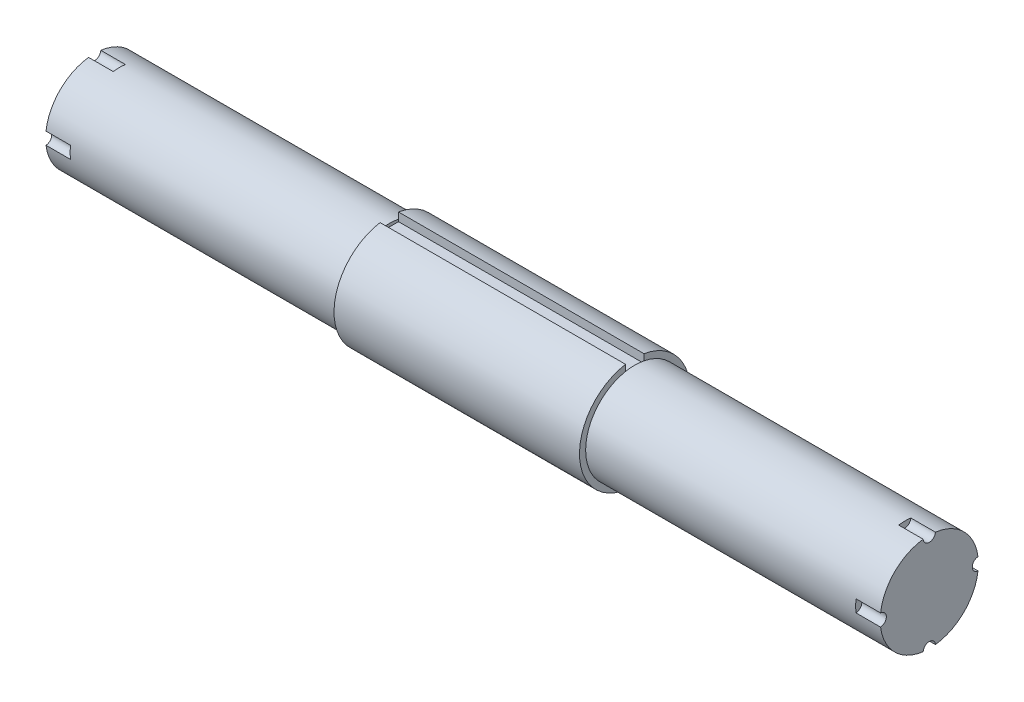
from build123d import *

# Parameters (mm, degrees)
SKETCH1_R               = 14.2875
BOSS_EXTRUDE1_DEPTH     = 31.75
CUT_EXTRUDE1_DEPTH      = 63.5
SKETCH3_R               = 12.7
BOSS_EXTRUDE2_DEPTH     = 76.2
SKETCH4_R               = 12.7
BOSS_EXTRUDE3_DEPTH     = 76.2
SKETCH5_R               = 1.5875
CUT_EXTRUDE2_DEPTH      = 6.35
CIRPATTERN1_COUNT       = 4
MIRROR1_COPY_1_SKETCH_R = 1.5875
MIRROR1_COPY_1_DEPTH    = 6.35
MIRROR1_COPY_2_SKETCH_R = 1.5875
MIRROR1_COPY_2_DEPTH    = 6.35
MIRROR1_COPY_3_SKETCH_R = 1.5875
MIRROR1_COPY_3_DEPTH    = 6.35


with BuildPart() as part:
    # Sketch1 → Boss-Extrude1 (new body, symmetric)
    with BuildSketch(Plane(origin=(0, 0, 0), x_dir=(0, 0, -1), z_dir=(1, 0, 0))):
        Circle(SKETCH1_R)
    extrude(amount=BOSS_EXTRUDE1_DEPTH, both=True)

    # Sketch2 → Cut-Extrude1 (cut)
    with BuildSketch(Plane(origin=(31.75, 0, 0), x_dir=(0, 0, -1), z_dir=(1, 0, 0))):
        with BuildLine():
            Line((0, 11.90625), (2.38125, 11.90625))
            Line((2.38125, 11.90625), (2.38125, 14.087664984))
            ThreePointArc((2.38125, 14.087664984), (0, 14.2875), (-2.38125, 14.087664984))
            Line((-2.38125, 14.087664984), (-2.38125, 11.90625))
            Line((-2.38125, 11.90625), (0, 11.90625))
        make_face()
    extrude(amount=-CUT_EXTRUDE1_DEPTH, mode=Mode.SUBTRACT)

    # Sketch3 → Boss-Extrude2 (add)
    with BuildSketch(Plane(origin=(31.75, 0, 0), x_dir=(0, 0, -1), z_dir=(1, 0, 0))):
        with Locations(Location((0, 0, 0), (0, 0, 100.806922875))):  # turned: the seam where the file's is
            Circle(SKETCH3_R)
    extrude(amount=BOSS_EXTRUDE2_DEPTH)

    # Sketch4 → Boss-Extrude3 (add)
    with BuildSketch(Plane.ZY.offset(31.75)):
        with Locations(Location((0, 0, 0), (0, 0, 79.193077125))):  # turned: the seam where the file's is
            Circle(SKETCH4_R)
    extrude(amount=BOSS_EXTRUDE3_DEPTH)

    # Sketch5 → Cut-Extrude2 (cut)
    with BuildSketch(Plane(origin=(107.95, 0, 0), x_dir=(0, 0, -1), z_dir=(1, 0, 0))):
        with Locations((0, 12.7)):
            Circle(SKETCH5_R)
    cut_extrude2 = extrude(amount=-CUT_EXTRUDE2_DEPTH, mode=Mode.SUBTRACT)

    # CirPattern1: Cut-Extrude2 ×4 about axis
    cirpattern1_axis = Axis((0, 0, 0), (1, 0, 0))
    for i in range(1, CIRPATTERN1_COUNT):
        add(cut_extrude2.rotate(cirpattern1_axis, i * 360 / CIRPATTERN1_COUNT), mode=Mode.SUBTRACT)

    # Mirror1: Cut-Extrude2 across plane
    add(cut_extrude2.mirror(Plane(origin=(0, 0, 0), x_dir=(0, 0, 1), z_dir=(1, 0, 0))), mode=Mode.SUBTRACT)

    # Mirror1 copy 1 sketch → Mirror1 copy 1 (cut)
    with BuildSketch(Plane(origin=(-107.95, 0, 0), x_dir=(0, 1, 0), z_dir=(-1, 0, 0))):
        with Locations((0, -12.7)):
            Circle(MIRROR1_COPY_1_SKETCH_R)
    extrude(amount=-MIRROR1_COPY_1_DEPTH, mode=Mode.SUBTRACT)

    # Mirror1 copy 2 sketch → Mirror1 copy 2 (cut)
    with BuildSketch(Plane.ZY.offset(107.95)):
        with Locations((0, -12.7)):
            Circle(MIRROR1_COPY_2_SKETCH_R)
    extrude(amount=-MIRROR1_COPY_2_DEPTH, mode=Mode.SUBTRACT)

    # Mirror1 copy 3 sketch → Mirror1 copy 3 (cut)
    with BuildSketch(Plane(origin=(-107.95, 0, 0), x_dir=(0, -1, 0), z_dir=(-1, 0, 0))):
        with Locations((0, -12.7)):
            Circle(MIRROR1_COPY_3_SKETCH_R)
    extrude(amount=-MIRROR1_COPY_3_DEPTH, mode=Mode.SUBTRACT)


solid = part.part
